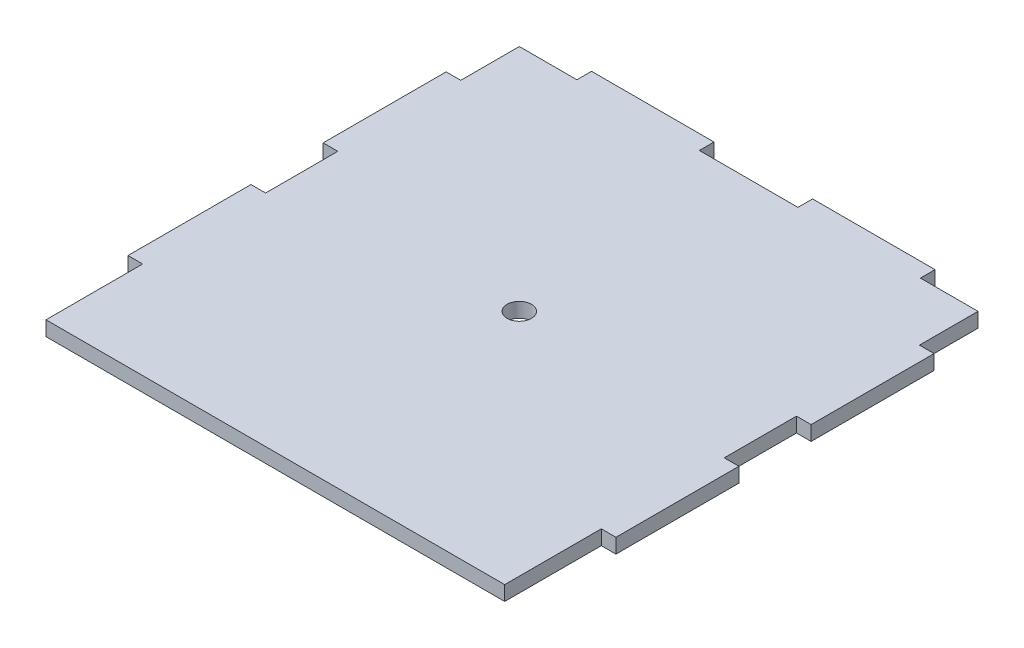
from build123d import *

# Parameters (mm, degrees)
SKETCH1_R           = 2.5
BOSS_EXTRUDE1_DEPTH = 3


with BuildPart() as part:
    # Sketch1 → Boss-Extrude1 (new body)
    with BuildSketch(Plane(origin=(0, 0, 0), x_dir=(1, 0, 0), z_dir=(0, 1, 0))):
        Polygon((3, 19.8), (3, 0), (97, 0), (97, 19.8), (100, 19.8), (100, 45), (97, 45), (97, 59.8), (100, 59.8), (100, 85), (97, 85), (97, 97), (85.2, 97), (85.2, 100), (60.1, 100), (60.1, 97), (39.9, 97), (39.9, 100), (14.8, 100), (14.8, 97), (3, 97), (3, 85), (0, 85), (0, 59.8), (3, 59.8), (3, 45), (0, 45), (0, 19.8), align=None)
        with Locations((50, 50)):
            Circle(SKETCH1_R, mode=Mode.SUBTRACT)
    extrude(amount=BOSS_EXTRUDE1_DEPTH)


solid = part.part
